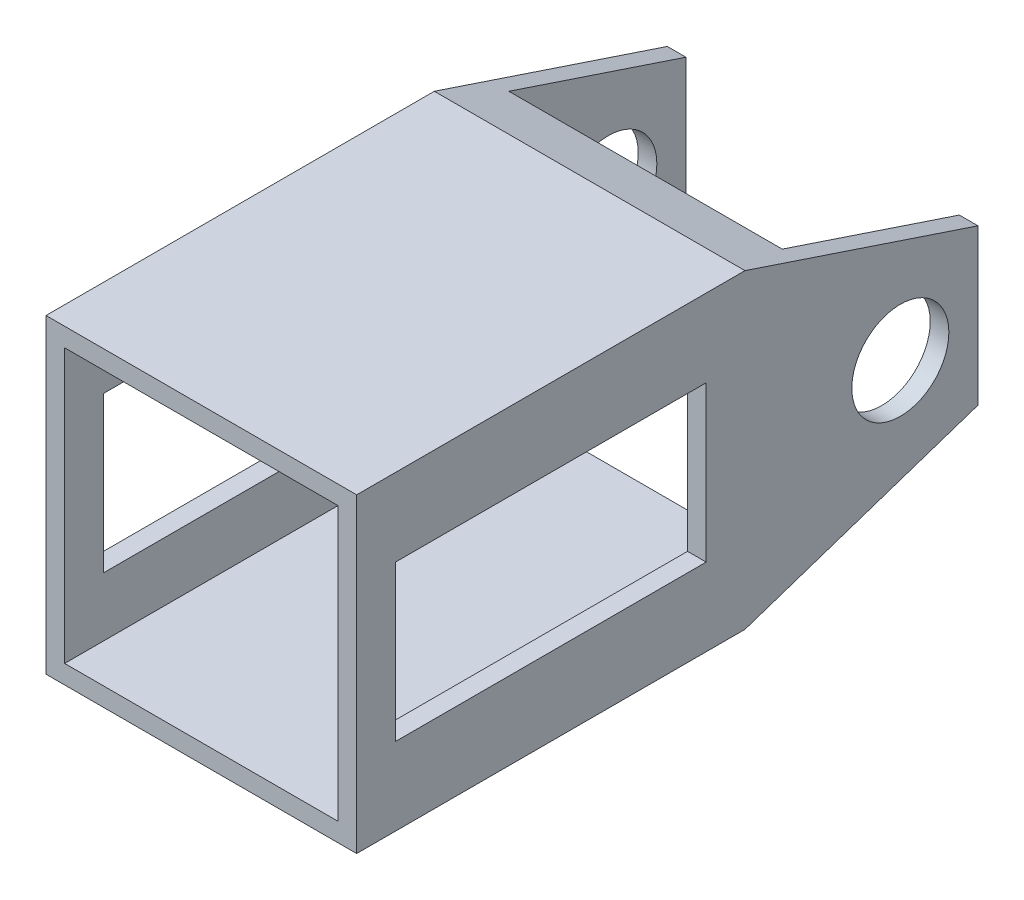
from build123d import *

# Parameters (mm, degrees)
SKETCH1_W           = 25.4
SKETCH1_H           = 25.4
SKETCH1_W_2         = 22.352
SKETCH1_H_2         = 22.352
BOSS_EXTRUDE1_DEPTH = 25.4
SKETCH2_R           = 3.96875
SKETCH2_W           = 25.4
SKETCH2_H           = 12.7
CUT_EXTRUDE1_DEPTH  = 26.4
CUT_EXTRUDE2_DEPTH  = 26.4


with BuildPart() as part:
    # Sketch1 → Boss-Extrude1 (new body, symmetric)
    with BuildSketch(Plane.XY):
        Rectangle(SKETCH1_W, SKETCH1_H)
        Rectangle(SKETCH1_W_2, SKETCH1_H_2, mode=Mode.SUBTRACT)
    extrude(amount=BOSS_EXTRUDE1_DEPTH, both=True)

    # Sketch2 → Cut-Extrude1 (cut, through all)
    with BuildSketch(Plane(origin=(12.7, 0, 0), x_dir=(0, 0, -1), z_dir=(1, 0, 0))):
        with Locations((19.05, 0)):
            Circle(SKETCH2_R)
        with Locations((-9.525, 0)):
            Rectangle(SKETCH2_W, SKETCH2_H)
    extrude(amount=-CUT_EXTRUDE1_DEPTH, mode=Mode.SUBTRACT)

    # Sketch3 → Cut-Extrude2 (cut, through all)
    with BuildSketch(Plane(origin=(12.7, 0, 0), x_dir=(0, 0, -1), z_dir=(1, 0, 0))):
        Polygon((6.35, 12.7), (25.4, 6.35), (25.4, 12.7), align=None)
        Polygon((25.4, -6.35), (25.4, -12.7), (6.35, -12.7), align=None)
    extrude(amount=-CUT_EXTRUDE2_DEPTH, mode=Mode.SUBTRACT)


solid = part.part
